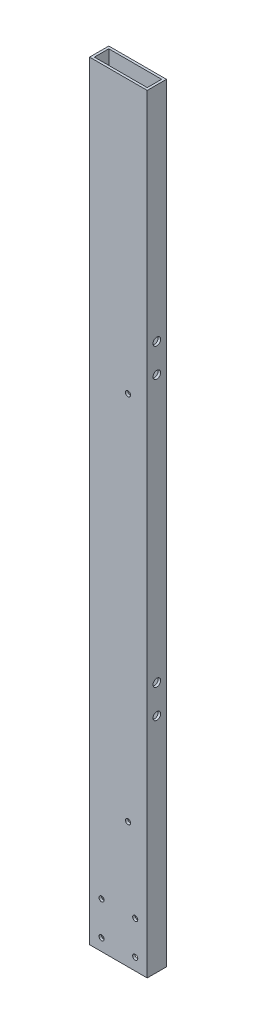
from build123d import *

# Parameters (mm, degrees)
SKETCH1_W           = 76.2
SKETCH1_H           = 25.4
SKETCH1_W_2         = 69.85
SKETCH1_H_2         = 19.05
BOSS_EXTRUDE1_DEPTH = 1016
SKETCH2_R           = 5.0419
CUT_EXTRUDE1_DEPTH  = 77.2
SKETCH3_R           = 3.3782
CUT_EXTRUDE2_DEPTH  = 26.4
SKETCH4_R           = 3.3782
CUT_EXTRUDE3_DEPTH  = 26.4


with BuildPart() as part:
    # Sketch1 → Boss-Extrude1 (new body)
    with BuildSketch(Plane(origin=(0, 0, 0), x_dir=(1, 0, 0), z_dir=(0, 1, 0))):
        with Locations((38.1, 12.7)):
            Rectangle(SKETCH1_W, SKETCH1_H)
        with Locations((38.1, 12.7)):
            Rectangle(SKETCH1_W_2, SKETCH1_H_2, mode=Mode.SUBTRACT)
    extrude(amount=BOSS_EXTRUDE1_DEPTH)

    # Sketch2 → Cut-Extrude1 (cut, through all)
    with BuildSketch(Plane(origin=(76.2, 0, 0), x_dir=(0, 0, -1), z_dir=(1, 0, 0))):
        with Locations((12.7, 293.6875)):
            Circle(SKETCH2_R)
        with Locations((12.7, 331.7875)):
            Circle(SKETCH2_R)
    cut_extrude1 = extrude(amount=-CUT_EXTRUDE1_DEPTH, mode=Mode.SUBTRACT)

    # Mirror1: Cut-Extrude1 across plane
    add(cut_extrude1.mirror(Plane(origin=(0, 508, 0), x_dir=(0, 0, 1), z_dir=(0, -1, 0))), mode=Mode.SUBTRACT)

    # Sketch3 → Cut-Extrude2 (cut, through all)
    with BuildSketch(Plane.XY):
        with Locations((15.875, 15.875)):
            Circle(SKETCH3_R)
        with Locations((15.875, 60.325)):
            Circle(SKETCH3_R)
        with Locations((60.325, 15.875)):
            Circle(SKETCH3_R)
        with Locations((60.325, 60.325)):
            Circle(SKETCH3_R)
    extrude(amount=-CUT_EXTRUDE2_DEPTH, mode=Mode.SUBTRACT)

    # Sketch4 → Cut-Extrude3 (cut, through all)
    with BuildSketch(Plane.XY):
        with Locations((50.8, 166.2938)):
            Circle(SKETCH4_R)
        with Locations((50.8, 656.0312)):
            Circle(SKETCH4_R)
    extrude(amount=-CUT_EXTRUDE3_DEPTH, mode=Mode.SUBTRACT)


solid = part.part
